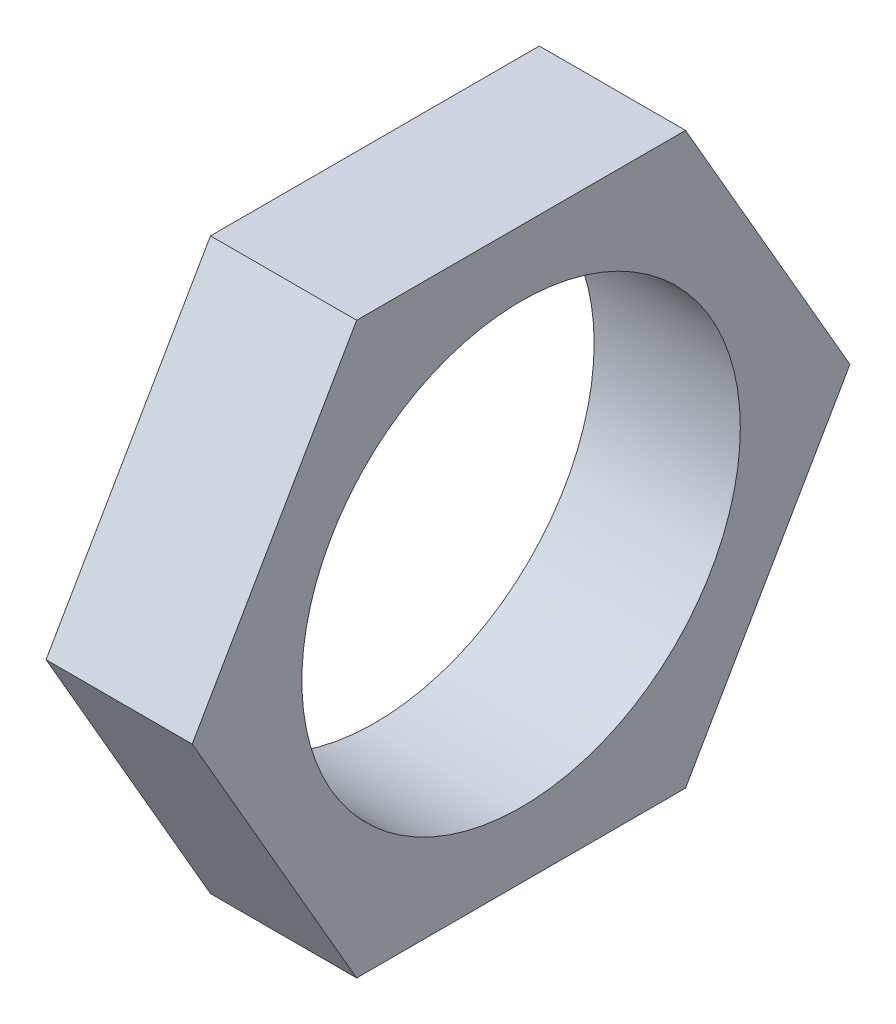
from build123d import *

# Parameters (mm, degrees)
SKETCH1_R           = 30
BOSS_EXTRUDE1_DEPTH = 20


with BuildPart() as part:
    # Sketch1 → Boss-Extrude1 (new body)
    with BuildSketch(Plane(origin=(0, 0, 0), x_dir=(0, 0, -1), z_dir=(1, 0, 0))):
        Polygon((45, 0), (22.5, 38.97114317), (-22.5, 38.97114317), (-45, 0), (-22.5, -38.97114317), (22.5, -38.97114317), align=None)
        Circle(SKETCH1_R, mode=Mode.SUBTRACT)
    extrude(amount=BOSS_EXTRUDE1_DEPTH)


solid = part.part
